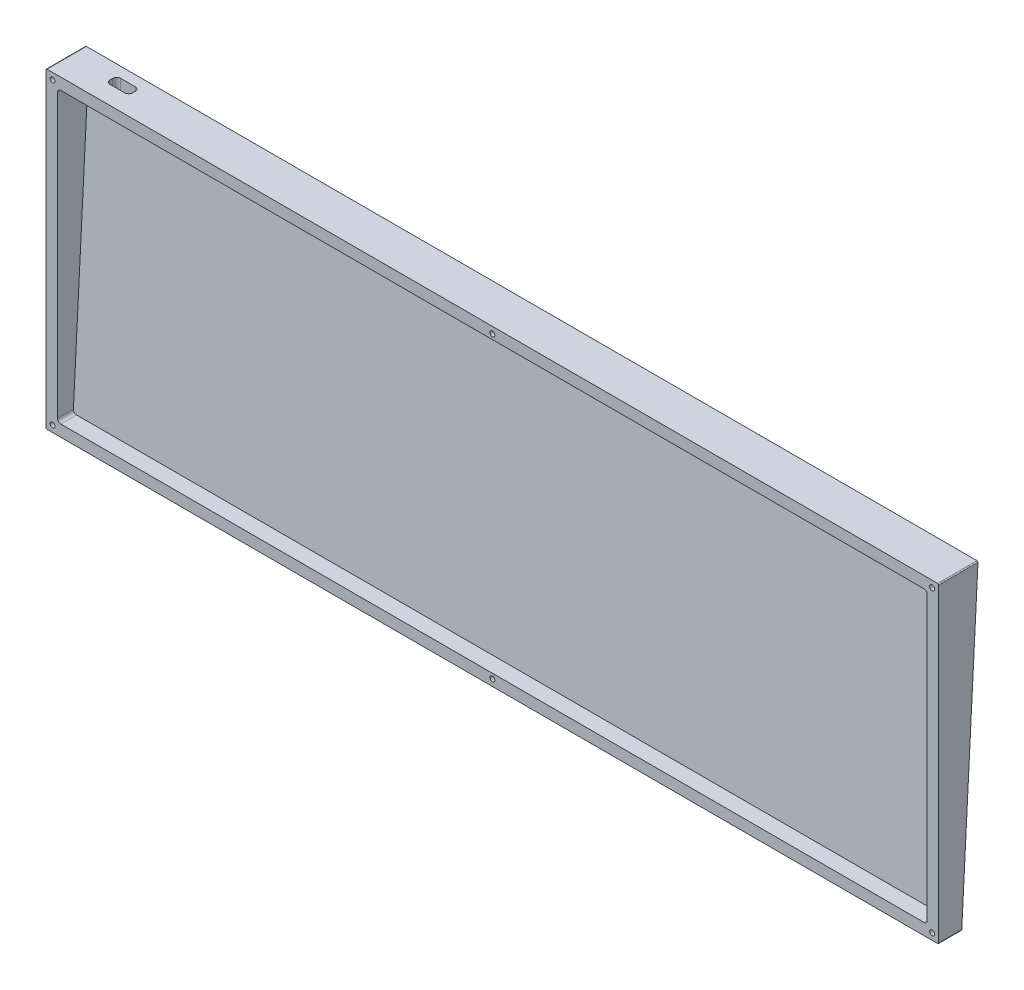
from build123d import *

# Parameters (mm, degrees)
SKETCH3_W               = 431.8
SKETCH3_H               = 150.876
BOSS_EXTRUDE2_DEPTH     = 19.05
CUT_EXTRUDE4_DEPTH      = 457.842377969
CUT_EXTRUDE5_DEPTH      = 414.600483388
CUT_EXTRUDE5_DEPTH_BACK = 414.600483388
SKETCH3_25_W            = 420.690716801
SKETCH3_25_H            = 139.766716802
BOSS_EXTRUDE3_REACH     = 458.842
M2_CLEARANCE_HOLE1_D    = 2.4
CUT_EXTRUDE8_DEPTH      = 10.16
CUT_EXTRUDE9_DEPTH      = 2.032
FILLET7_R               = 1.5875
FILLET8_R               = 0.508
CUT_EXTRUDE10_REACH     = 416.654


with BuildPart() as part:
    # Sketch3 → Boss-Extrude2 (new body)
    with BuildSketch(Plane.XY):
        with Locations((169.861119801, 72.517452108)):
            Rectangle(SKETCH3_W, SKETCH3_H)
    extrude(amount=BOSS_EXTRUDE2_DEPTH)

    # Sketch11 → Cut-Extrude4 (cut, through all)
    with BuildSketch(Plane.ZY.offset(46.038880199)):
        Polygon((7.907076107, -2.920547892), (0, 147.955452108), (0, -2.920547892), align=None)
    extrude(amount=-CUT_EXTRUDE4_DEPTH, mode=Mode.SUBTRACT)

    # Sketch3_25 → Cut-Extrude5 (cut, two sides: drawn at the far end of the back side and taken through both)
    with BuildSketch(Plane.XY.offset(-CUT_EXTRUDE5_DEPTH_BACK)):
        with Locations((169.861119801, 72.517452108)):
            Rectangle(SKETCH3_25_W, SKETCH3_25_H)
    extrude(amount=CUT_EXTRUDE5_DEPTH + CUT_EXTRUDE5_DEPTH_BACK, mode=Mode.SUBTRACT)

    # Sketch11_3 → Boss-Extrude3 (add, up to next)
    with BuildSketch(Plane.ZY.offset(46.038880199), mode=Mode.PRIVATE) as boss_extrude3_sk1:
        Polygon((3.815228638, 147.955452108), (0, 147.955452108), (7.907076107, -2.920547892), (11.722304745, -2.920547892), align=None)
    boss_extrude3_tool1 = extrude(boss_extrude3_sk1.sketch, amount=-BOSS_EXTRUDE3_REACH, mode=Mode.PRIVATE) - part.part
    add(boss_extrude3_tool1.solids().sort_by_distance((-46.03888, 72.517452, 5.861152))[0])

    # M2 Clearance Hole1 (through all)
    with Locations(Plane.XY.offset(19.05)):
        with Locations((-42.863880199, 144.780452108), (169.861119801, 144.780452108), (382.586119801, 144.780452108), (382.586119801, 0.254452108), (169.861119801, 0.254452108), (-42.863880199, 0.254452108)):
            Hole(M2_CLEARANCE_HOLE1_D / 2)

    # Sketch3_27 → Cut-Extrude8 (cut)
    with BuildSketch(Plane.XY):
        with BuildLine():
            Line((-44.795957036, 1.196057231), (-42.281485322, 3.710528944))
            ThreePointArc((-42.281485322, 3.710528944), (-39.407803363, 3.710528944), (-39.407803363, 0.836846986))
            Line((-39.407803363, 0.836846986), (-41.922275077, -1.677624728))
            ThreePointArc((-41.922275077, -1.677624728), (-44.795957036, -1.677624728), (-44.795957036, 1.196057231))
        make_face()
        with BuildLine():
            Line((168.083119801, 2.286452108), (171.639119801, 2.286452108))
            ThreePointArc((171.639119801, 2.286452108), (173.671119801, 0.254452108), (171.639119801, -1.777547892))
            Line((171.639119801, -1.777547892), (168.083119801, -1.777547892))
            ThreePointArc((168.083119801, -1.777547892), (166.051119801, 0.254452108), (168.083119801, 2.286452108))
        make_face()
        with BuildLine():
            Line((382.003724923, 3.710528944), (384.518196637, 1.196057231))
            ThreePointArc((384.518196637, 1.196057231), (384.518196637, -1.677624728), (381.644514678, -1.677624728))
            Line((381.644514678, -1.677624728), (379.130042964, 0.836846986))
            ThreePointArc((379.130042964, 0.836846986), (379.130042964, 3.710528944), (382.003724923, 3.710528944))
        make_face()
    extrude(amount=CUT_EXTRUDE8_DEPTH, mode=Mode.SUBTRACT)

    # Sketch3_28 → Cut-Extrude9 (cut)
    with BuildSketch(Plane.XY):
        with BuildLine():
            Line((-39.407803363, 144.198057231), (-41.922275077, 146.712528944))
            ThreePointArc((-41.922275077, 146.712528944), (-44.795957036, 146.712528944), (-44.795957036, 143.838846986))
            Line((-44.795957036, 143.838846986), (-42.281485322, 141.324375272))
            ThreePointArc((-42.281485322, 141.324375272), (-39.407803363, 141.324375272), (-39.407803363, 144.198057231))
        make_face()
        with BuildLine():
            ThreePointArc((379.130042964, 144.198057231), (379.130042964, 141.324375272), (382.003724923, 141.324375272))
            Line((382.003724923, 141.324375272), (384.518196637, 143.838846986))
            ThreePointArc((384.518196637, 143.838846986), (384.518196637, 146.712528944), (381.644514678, 146.712528944))
            Line((381.644514678, 146.712528944), (379.130042964, 144.198057231))
        make_face()
        with BuildLine():
            Line((171.639119801, 146.812452108), (168.083119801, 146.812452108))
            ThreePointArc((168.083119801, 146.812452108), (166.051119801, 144.780452108), (168.083119801, 142.748452108))
            Line((168.083119801, 142.748452108), (171.639119801, 142.748452108))
            ThreePointArc((171.639119801, 142.748452108), (173.671119801, 144.780452108), (171.639119801, 146.812452108))
        make_face()
    extrude(amount=CUT_EXTRUDE9_DEPTH, mode=Mode.SUBTRACT)

    # Fillet7
    fillet7_edges = [part.edges().sort_by_distance(p)[0] for p in [
        (380.206478201, 2.634093707, 15.240599157),
        (380.206478201, 142.400810509, 11.578167535),
        (-40.4842386, 2.634093707, 15.240599157),
        (-40.4842386, 142.400810509, 11.578167535),
    ]]
    fillet(fillet7_edges, radius=FILLET7_R)

    # Fillet8
    fillet8_edges = [part.edges().sort_by_distance(p)[0] for p in [
        (-46.038880199, -2.920547892, 13.478538054),
        (385.761119801, -2.920547892, 13.478538054),
        (385.761119801, 147.955452108, 9.525),
        (-46.038880199, 147.955452108, 9.525),
    ]]
    fillet(fillet8_edges, radius=FILLET8_R)

    # Sketch18 → Cut-Extrude10 (cut, up to next)
    with BuildSketch(Plane(origin=(0, 147.955452108, 0), x_dir=(1, 0, 0), z_dir=(0, 1, 0)), mode=Mode.PRIVATE) as cut_extrude10_sk1:
        with BuildLine():
            Line((-16.828880199, -10.16), (-23.940880199, -10.16))
            ThreePointArc((-23.940880199, -10.16), (-25.287918618, -9.602038418), (-25.845880199, -8.255))
            Line((-25.845880199, -8.255), (-25.845880199, -6.985))
            ThreePointArc((-25.845880199, -6.985), (-25.287918618, -5.637961582), (-23.940880199, -5.08))
            Line((-23.940880199, -5.08), (-16.828880199, -5.08))
            ThreePointArc((-16.828880199, -5.08), (-15.481841781, -5.637961582), (-14.923880199, -6.985))
            Line((-14.923880199, -6.985), (-14.923880199, -8.255))
            ThreePointArc((-14.923880199, -8.255), (-15.481841781, -9.602038418), (-16.828880199, -10.16))
        make_face()
    cut_extrude10_tool1 = extrude(cut_extrude10_sk1.sketch, amount=-CUT_EXTRUDE10_REACH, mode=Mode.PRIVATE) & part.part
    add(cut_extrude10_tool1.solids().sort_by_distance((-20.38488, 147.955452, 7.62))[0], mode=Mode.SUBTRACT)


solid = part.part
